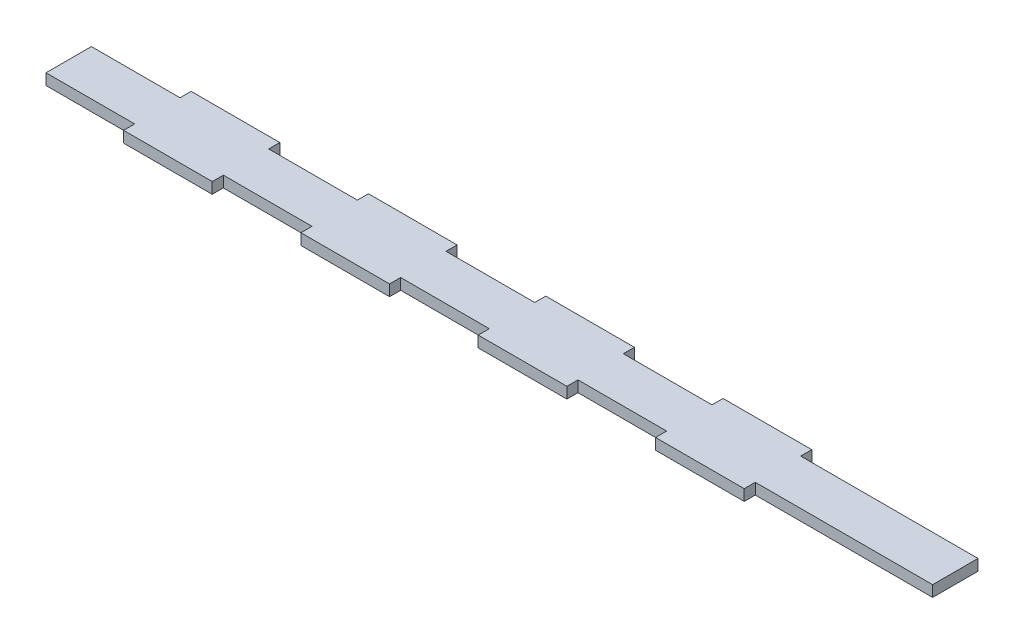
from build123d import *

# Parameters (mm, degrees)
BOSS_EXTRUDE1_DEPTH = 1.5875


with BuildPart() as part:
    # Sketch1 → Boss-Extrude1 (new body, symmetric)
    with BuildSketch(Plane(origin=(0, 0, 0), x_dir=(1, 0, 0), z_dir=(0, 1, 0))):
        Polygon((-114.3, 6.5), (-114.3, -6.5), (-88.9, -6.5), (-88.9, -9.675), (-63.5, -9.675), (-63.5, -6.5), (-38.1, -6.5), (-38.1, -9.675), (-12.7, -9.675), (-12.7, -6.5), (12.7, -6.5), (12.7, -9.675), (38.1, -9.675), (38.1, -6.5), (63.5, -6.5), (63.5, -9.675), (88.9, -9.675), (88.9, -6.5), (139.7, -6.5), (139.7, 6.5), (88.9, 6.5), (88.9, 9.675), (63.5, 9.675), (63.5, 6.5), (38.1, 6.5), (38.1, 9.675), (12.7, 9.675), (12.7, 6.5), (-12.7, 6.5), (-12.7, 9.675), (-38.1, 9.675), (-38.1, 6.5), (-63.5, 6.5), (-63.5, 9.675), (-88.9, 9.675), (-88.9, 6.5), align=None)
    extrude(amount=BOSS_EXTRUDE1_DEPTH, both=True)


solid = part.part
